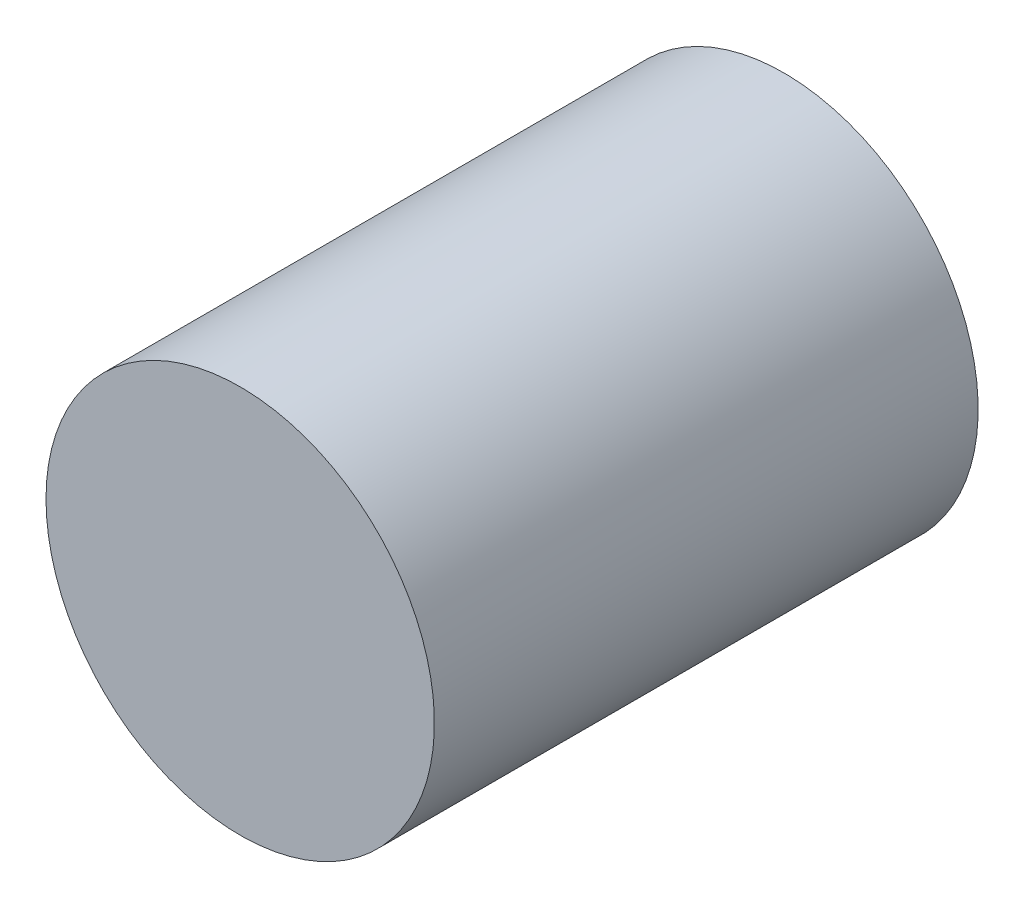
from build123d import *

# Parameters (mm, degrees)
SKETCH1_R                = 5
BOSS_EXTRUDE1_DEPTH      = 7
BOSS_EXTRUDE1_DEPTH_BACK = 7


with BuildPart() as part:
    # Sketch1 → Boss-Extrude1 (new body, two sides)
    with BuildSketch(Plane(origin=(0, 0, 2.5), x_dir=(-1, 0, 0), z_dir=(0, 0, -1))) as boss_extrude1_sk:
        with Locations((0, 92.5)):
            Circle(SKETCH1_R)
    extrude(amount=BOSS_EXTRUDE1_DEPTH)
    extrude(boss_extrude1_sk.sketch, amount=-BOSS_EXTRUDE1_DEPTH_BACK)


solid = part.part
